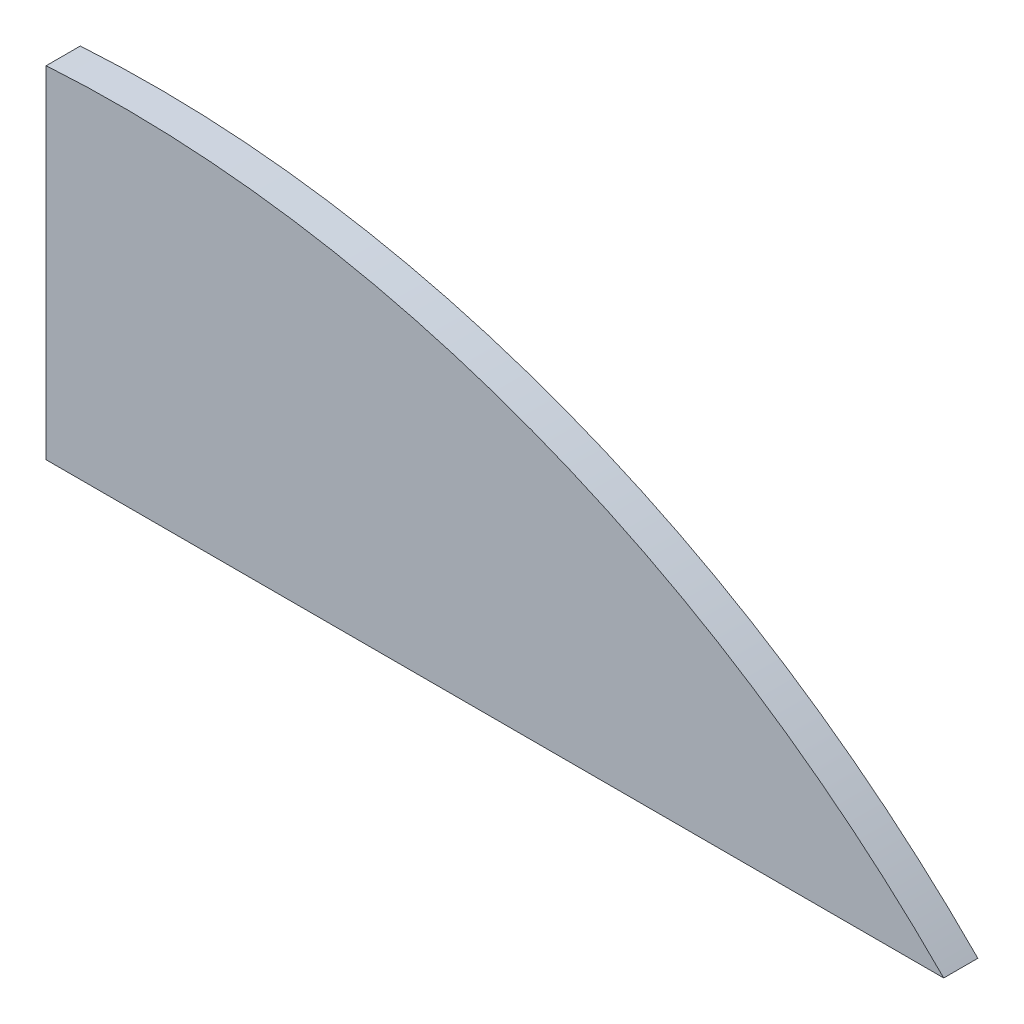
from build123d import *

# Parameters (mm, degrees)
BOSS_EXTRUDE1_DEPTH = 1


with BuildPart() as part:
    # Sketch1 → Boss-Extrude1 (new body)
    with BuildSketch(Plane.XY):
        with BuildLine():
            Line((0, 0), (0, 10))
            ThreePointArc((0, 10), (14.237787239, 7.860880439), (26.3, 0))
            Line((26.3, 0), (0, 0))
        make_face()
    extrude(amount=BOSS_EXTRUDE1_DEPTH)


solid = part.part
